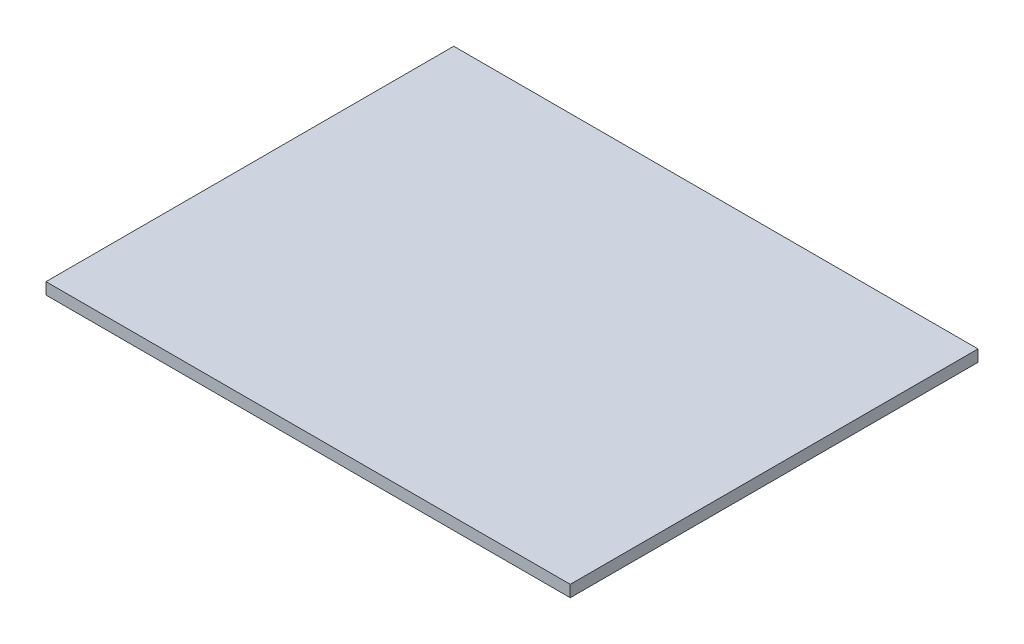
from build123d import *

# Parameters (mm, degrees)
CROQUIS2_W              = 90
CROQUIS2_H              = 70
SALIENTE_EXTRUIR1_DEPTH = 2


with BuildPart() as part:
    # Croquis2 → Saliente-Extruir1 (new body)
    with BuildSketch(Plane(origin=(0, 0, 0), x_dir=(1, 0, 0), z_dir=(0, 1, 0))):
        Rectangle(CROQUIS2_W, CROQUIS2_H)
    extrude(amount=SALIENTE_EXTRUIR1_DEPTH)


solid = part.part
